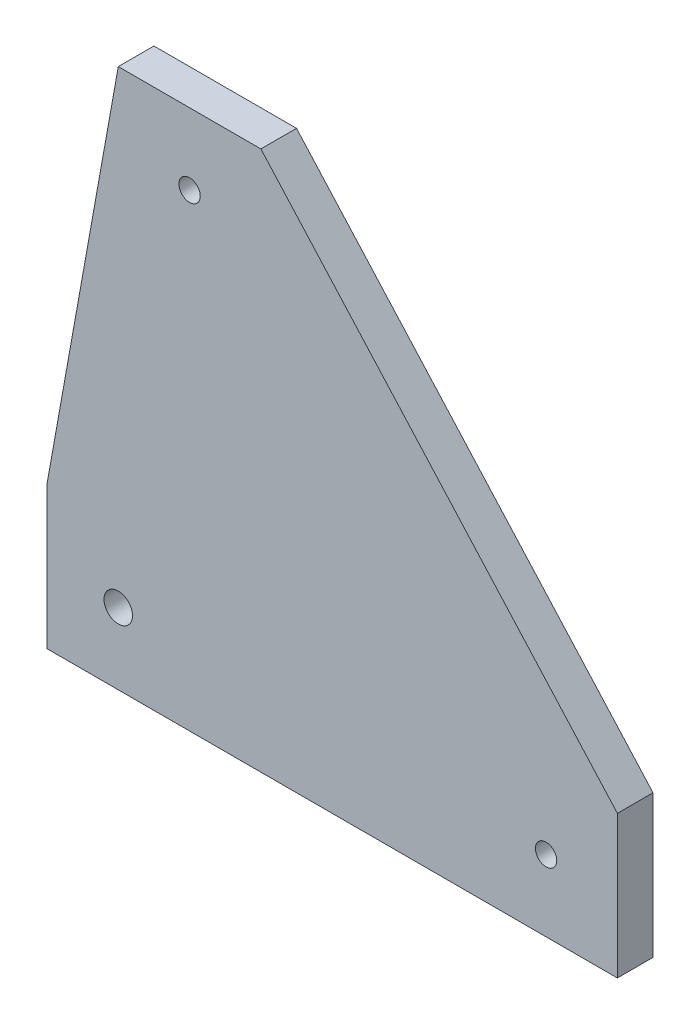
from build123d import *

# Parameters (mm, degrees)
SKETCH1_R           = 2
SKETCH1_R_2         = 1.5
BOSS_EXTRUDE1_DEPTH = 5


with BuildPart() as part:
    # Sketch1 → Boss-Extrude1 (new body)
    with BuildSketch(Plane.XY):
        Polygon((-26.915412931, 65.706251458), (-6.915412931, 65.706251458), (43.084587069, 10), (43.084587069, -10), (-36.915412931, -10), (-36.915412931, 10), align=None)
        with Locations((-26.915412931, 0)):
            Circle(SKETCH1_R, mode=Mode.SUBTRACT)
        with Locations((33.084587069, 0)):
            Circle(SKETCH1_R_2, mode=Mode.SUBTRACT)
        with Locations((-16.915412931, 55.706251458)):
            Circle(SKETCH1_R_2, mode=Mode.SUBTRACT)
    extrude(amount=BOSS_EXTRUDE1_DEPTH)


solid = part.part
